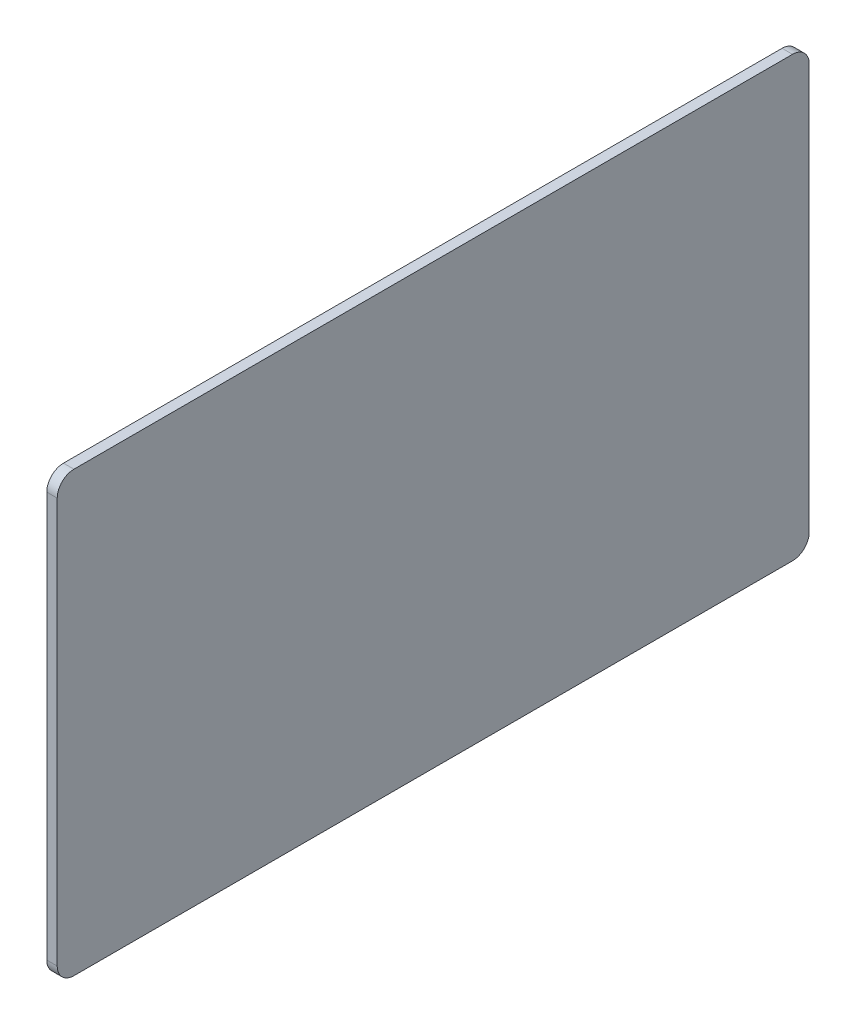
from build123d import *

# Parameters (mm, degrees)
SKETCH1_W           = 114.3
SKETCH1_H           = 66.675
BOSS_EXTRUDE1_DEPTH = 1.5875
FILLET1_R           = 2.54


with BuildPart() as part:
    # Sketch1 → Boss-Extrude1 (new body)
    with BuildSketch(Plane(origin=(0, 0, 0), x_dir=(0, 0, -1), z_dir=(1, 0, 0))):
        Rectangle(SKETCH1_W, SKETCH1_H)
    extrude(amount=BOSS_EXTRUDE1_DEPTH)

    # Fillet1
    fillet1_edges = [part.edges().sort_by_distance(p)[0] for p in [
        (0.79375, -33.3375, -57.15),
        (0.79375, -33.3375, 57.15),
        (0.79375, 33.3375, 57.15),
        (0.79375, 33.3375, -57.15),
    ]]
    fillet(fillet1_edges, radius=FILLET1_R)


solid = part.part
